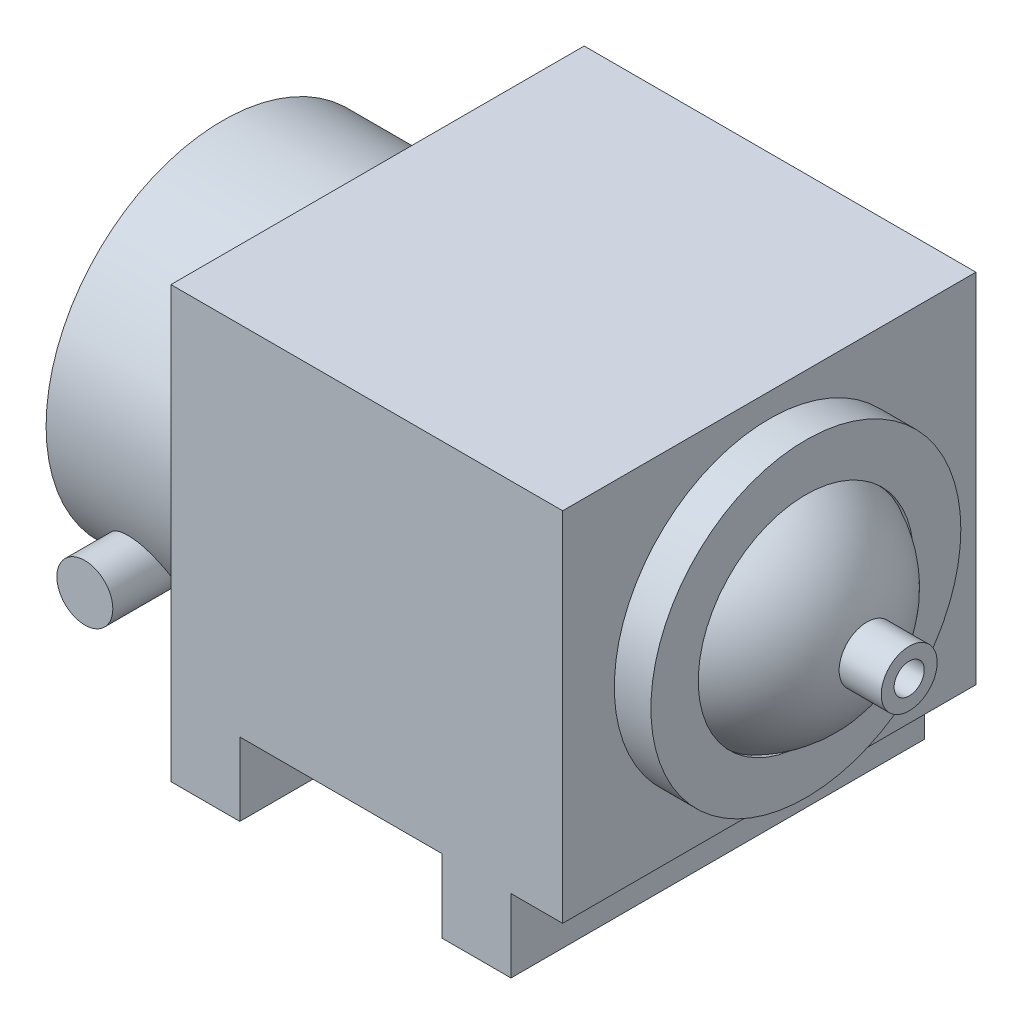
from build123d import *

# Parameters (mm, degrees)
SKETCH1_W             = 16
SKETCH1_H             = 96
SKETCH1_R             = 3
BOSS_EXTRUDE1_DEPTH   = 17
BOSS_EXTRUDE1_2_DEPTH = 17
SKETCH2_W             = 91
SKETCH2_H             = 96
BOSS_EXTRUDE2_DEPTH   = 83
SKETCH3_R             = 41
BOSS_EXTRUDE3_DEPTH   = 36
BOSS_EXTRUDE4_REACH   = 98
SKETCH4_R             = 6.5
SKETCH5_R             = 36
BOSS_EXTRUDE5_DEPTH   = 8.5
SKETCH6_R             = 25
CUT_EXTRUDE1_DEPTH    = 1
DOME1_FACE_RADIUS     = 25
DOME1_HEIGHT          = 16
SKETCH7_R             = 6.5
SKETCH7_R_2           = 3.5
BOSS_EXTRUDE6_DEPTH   = 9


with BuildPart() as part:
    # Sketch1 → Boss-Extrude1 (new body)
    with BuildSketch(Plane(origin=(0, 0, 0), x_dir=(1, 0, 0), z_dir=(0, 1, 0))):
        with Locations((-31.5, 0)):
            Rectangle(SKETCH1_W, SKETCH1_H)
        with Locations((-32, 40.5)):
            Circle(SKETCH1_R, mode=Mode.SUBTRACT)
        with Locations((-32, -40.5)):
            Circle(SKETCH1_R, mode=Mode.SUBTRACT)
    extrude(amount=BOSS_EXTRUDE1_DEPTH)



with BuildPart() as body_2:
    # Sketch1 → Boss-Extrude1 2 (new body)
    with BuildSketch(Plane(origin=(0, 0, 0), x_dir=(1, 0, 0), z_dir=(0, 1, 0))):
        with Locations((31.5, 0)):
            Rectangle(SKETCH1_W, SKETCH1_H)
        with Locations((32, 40.5)):
            Circle(SKETCH1_R, mode=Mode.SUBTRACT)
        with Locations((32, -40.5)):
            Circle(SKETCH1_R, mode=Mode.SUBTRACT)
    extrude(amount=BOSS_EXTRUDE1_2_DEPTH)


with BuildPart() as part_1:
    add(part.part)

    add(body_2.part)  # Boss-Extrude2 merges body 2
    # Sketch2 → Boss-Extrude2 (add)
    with BuildSketch(Plane(origin=(0, 17, 0), x_dir=(1, 0, 0), z_dir=(0, 1, 0))):
        with Locations((6, 0)):
            Rectangle(SKETCH2_W, SKETCH2_H)
    extrude(amount=BOSS_EXTRUDE2_DEPTH)

    # Sketch3 → Boss-Extrude3 (add)
    with BuildSketch(Plane.ZY.offset(39.5)):
        with Locations((0, 50)):
            Circle(SKETCH3_R)
    extrude(amount=BOSS_EXTRUDE3_DEPTH)

    # Sketch4 → Boss-Extrude4 (add, up to next)
    with BuildSketch(Plane.XY.offset(48), mode=Mode.PRIVATE) as boss_extrude4_sk1:
        with Locations((-59.5, 28)):
            Circle(SKETCH4_R)
    boss_extrude4_tool1 = extrude(boss_extrude4_sk1.sketch, amount=-BOSS_EXTRUDE4_REACH, mode=Mode.PRIVATE) - part_1.part
    add(boss_extrude4_tool1.solids().sort_by_distance((-59.5, 28, 48))[0])

    # Sketch5 → Boss-Extrude5 (add)
    with BuildSketch(Plane(origin=(51.5, 0, 0), x_dir=(0, 0, -1), z_dir=(1, 0, 0))):
        with Locations((0, 58.5)):
            Circle(SKETCH5_R)
    extrude(amount=BOSS_EXTRUDE5_DEPTH)

    # Sketch6 → Cut-Extrude1 (cut)
    with BuildSketch(Plane(origin=(60, 0, 0), x_dir=(0, 0, -1), z_dir=(1, 0, 0))):
        with Locations((0, 58.5)):
            Circle(SKETCH6_R)
    extrude(amount=-CUT_EXTRUDE1_DEPTH, mode=Mode.SUBTRACT)

    # Dome1: a dome of height H over a round flat face of radius A is a cap of a sphere of radius (A * A + H * H) / (2 * H)
    dome1_r = (DOME1_FACE_RADIUS * DOME1_FACE_RADIUS + DOME1_HEIGHT * DOME1_HEIGHT) / (2 * DOME1_HEIGHT)
    dome1_base = Plane((59, 58.5, 0), z_dir=(1, 0, 0))
    with Locations(dome1_base.offset(DOME1_HEIGHT - dome1_r)):
        dome1_ball = Sphere(dome1_r, mode=Mode.PRIVATE)
    add(split(dome1_ball, bisect_by=dome1_base, keep=Keep.TOP, mode=Mode.PRIVATE))

    # Sketch7 → Boss-Extrude6 (add, symmetric)
    with BuildSketch(Plane(origin=(75, 0, 0), x_dir=(0, 0, -1), z_dir=(1, 0, 0))):
        with Locations((0, 58.5)):
            Circle(SKETCH7_R)
        with Locations((0, 58.5)):
            Circle(SKETCH7_R_2, mode=Mode.SUBTRACT)
    extrude(amount=BOSS_EXTRUDE6_DEPTH, both=True)


solid = part_1.part
